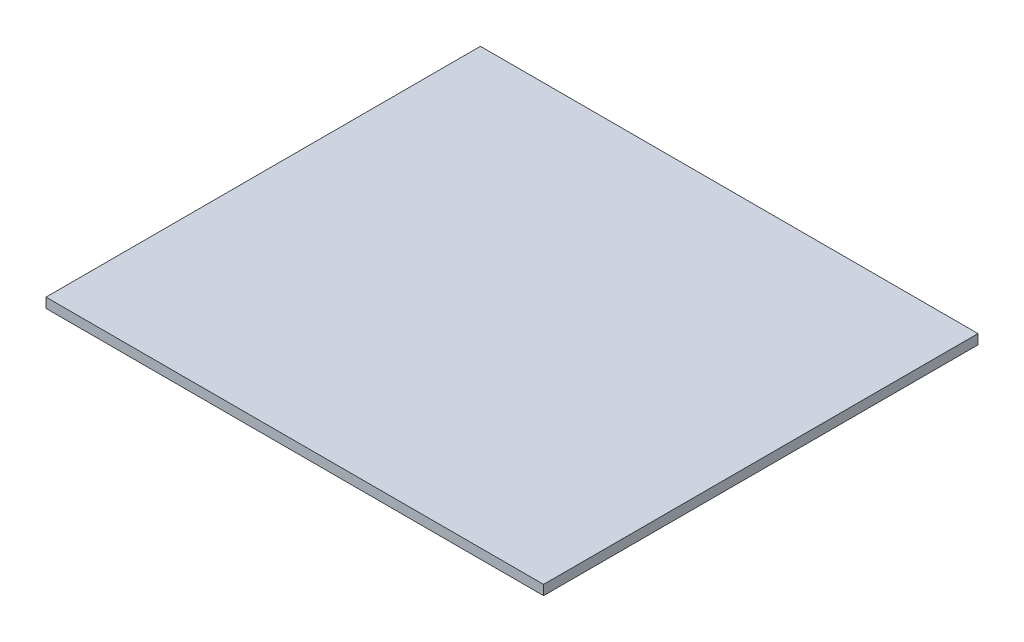
from build123d import *

# Parameters (mm, degrees)
SKETCH1_W           = 838.2
SKETCH1_H           = 731.8375
BOSS_EXTRUDE1_DEPTH = 19.05
CHAMFER1_SIZE       = 2.54


with BuildPart() as part:
    # Sketch1 → Boss-Extrude1 (new body)
    with BuildSketch(Plane(origin=(0, 0, 0), x_dir=(1, 0, 0), z_dir=(0, 1, 0))):
        with Locations((419.1, 365.91875)):
            Rectangle(SKETCH1_W, SKETCH1_H)
    extrude(amount=BOSS_EXTRUDE1_DEPTH)

    # Chamfer1
    chamfer1_edges = [part.edges().sort_by_distance(p)[0] for p in [
        (419.1, 0, -731.8375),
        (838.2, 0, -365.91875),
        (419.1, 0, 0),
        (0, 0, -365.91875),
    ]]
    chamfer(chamfer1_edges, length=CHAMFER1_SIZE)


solid = part.part
